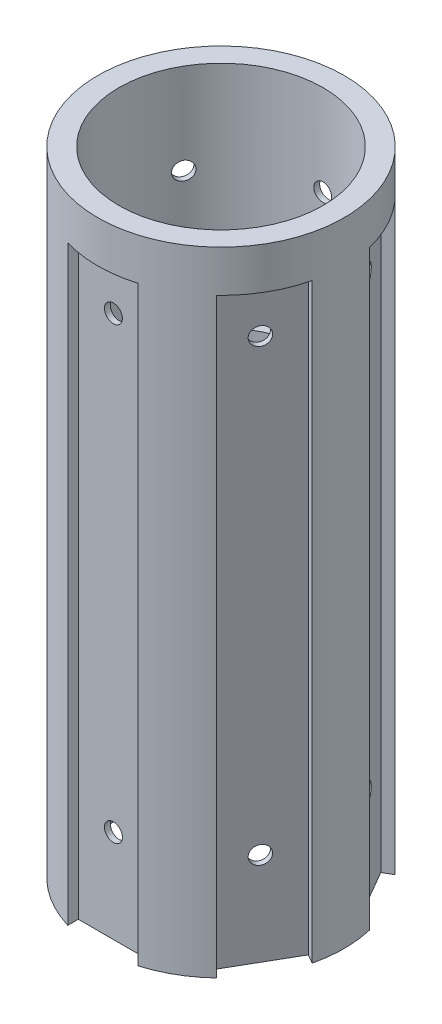
from build123d import *

# Parameters (mm, degrees)
SKETCH1_R               = 23.36
BOSS_EXTRUDE1_DEPTH     = 120
SHELL1_T                = -4
BOSS_EXTRUDE2_START     = -78
BOSS_EXTRUDE2_DEPTH     = 28
CUT_EXTRUDE2_START      = -3
SKETCH3_W               = 13.306682786
SKETCH3_H               = 112.078747136
CUT_EXTRUDE2_DEPTH      = 3
CIRPATTERN1_COUNT       = 6
CUT_EXTRUDE3_REACH      = 131.848
CUT_EXTRUDE3_END_RADIUS = 19.36
SKETCH4_R               = 1.7
CIRPATTERN2_COUNT       = 6


with BuildPart() as part:
    # Sketch1 → Boss-Extrude1 (new body)
    with BuildSketch(Plane(origin=(0, 0, 0), x_dir=(1, 0, 0), z_dir=(0, 1, 0))):
        with Locations(Location((0, 0, 0), (0, 0, 270))):
            Circle(SKETCH1_R)
    extrude(amount=BOSS_EXTRUDE1_DEPTH)

    # Shell1
    shell1_openings = [part.faces().sort_by_distance(p)[0] for p in [
        (0, 120, 0),
        (0, 0, 0),
    ]]
    offset(amount=SHELL1_T, openings=shell1_openings, kind=Kind.INTERSECTION)

    # Sketch2 → Boss-Extrude2 (add)
    with BuildSketch(Plane.XZ.offset(BOSS_EXTRUDE2_START)):
        with BuildLine():
            Line((-6.645158283, -18.183824444), (-5.892390902, -16.239003125))
            ThreePointArc((-5.892390902, -16.239003125), (-14.960585543, -8.63749809), (-17.00958469, 3.016541352))
            Line((-17.00958469, 3.016541352), (-19.070233048, 3.337036337))
            ThreePointArc((-19.070233048, 3.337036337), (-16.766251817, -9.68), (-6.645158283, -18.183824444))
        make_face()
        with BuildLine():
            ThreePointArc((17.00958469, 3.016541352), (14.960585543, -8.63749809), (5.892390902, -16.239003125))
            Line((5.892390902, -16.239003125), (6.645158283, -18.183824444))
            ThreePointArc((6.645158283, -18.183824444), (16.766251817, -9.68), (19.070233048, 3.337036337))
            Line((19.070233048, 3.337036337), (17.00958469, 3.016541352))
        make_face()
        with BuildLine():
            Line((-12.425074765, 14.846788107), (-11.117193788, 13.222461773))
            ThreePointArc((-11.117193788, 13.222461773), (0, 17.274996181), (11.117193788, 13.222461773))
            Line((11.117193788, 13.222461773), (12.425074765, 14.846788107))
            ThreePointArc((12.425074765, 14.846788107), (0, 19.36), (-12.425074765, 14.846788107))
        make_face()
    extrude(amount=BOSS_EXTRUDE2_DEPTH)

    # Sketch3 → Cut-Extrude2 (cut)
    with BuildSketch(Plane(origin=(0, 0, -26.4), x_dir=(-1, 0, 0), z_dir=(0, 0, -1)).offset(CUT_EXTRUDE2_START)):
        with Locations((0, 56.039373568)):
            Rectangle(SKETCH3_W, SKETCH3_H)
    cut_extrude2 = extrude(amount=-CUT_EXTRUDE2_DEPTH, mode=Mode.SUBTRACT)

    # CirPattern1: Cut-Extrude2 ×6 about axis
    cirpattern1_axis = Axis((0, 0, 0), (0, 1, 0))
    for i in range(1, CIRPATTERN1_COUNT):
        add(cut_extrude2.rotate(cirpattern1_axis, i * 360 / CIRPATTERN1_COUNT), mode=Mode.SUBTRACT)

    # Cut-Extrude3: up to this cylinder (the profile starts outside it)
    cut_extrude3_end = Plane(origin=(0, 60.2277495, 0), z_dir=(0, -1, 0)) * Cylinder(CUT_EXTRUDE3_END_RADIUS, 388.602281, mode=Mode.PRIVATE)
    # Sketch4 → Cut-Extrude3 (cut, up to the surface)
    with BuildSketch(Plane(origin=(0, 0, -20.4), x_dir=(-1, 0, 0), z_dir=(0, 0, -1)), mode=Mode.PRIVATE) as cut_extrude3_sk1:
        with Locations((0, 102.820889633)):
            Circle(SKETCH4_R)
    cut_extrude3_tool1 = extrude(cut_extrude3_sk1.sketch, amount=-CUT_EXTRUDE3_REACH, mode=Mode.PRIVATE) - cut_extrude3_end
    # Sketch4 → Cut-Extrude3 (cut, up to the surface)
    with BuildSketch(Plane(origin=(0, 0, -20.4), x_dir=(-1, 0, 0), z_dir=(0, 0, -1)), mode=Mode.PRIVATE) as cut_extrude3_sk2:
        with Locations((0, 17.634608904)):
            Circle(SKETCH4_R)
    cut_extrude3_tool2 = extrude(cut_extrude3_sk2.sketch, amount=-CUT_EXTRUDE3_REACH, mode=Mode.PRIVATE) - cut_extrude3_end
    cut_extrude3 = cut_extrude3_tool1.solids().sort_by_distance((0, 102.82089, -20.4))[0] + cut_extrude3_tool2.solids().sort_by_distance((0, 17.634609, -20.4))[0]
    add(cut_extrude3, mode=Mode.SUBTRACT)

    # CirPattern2: Cut-Extrude3 ×6 about axis
    cirpattern2_axis = Axis((0, 120, 0), (0, -1, 0))
    for i in range(1, CIRPATTERN2_COUNT):
        add(cut_extrude3.rotate(cirpattern2_axis, i * 360 / CIRPATTERN2_COUNT), mode=Mode.SUBTRACT)


solid = part.part
